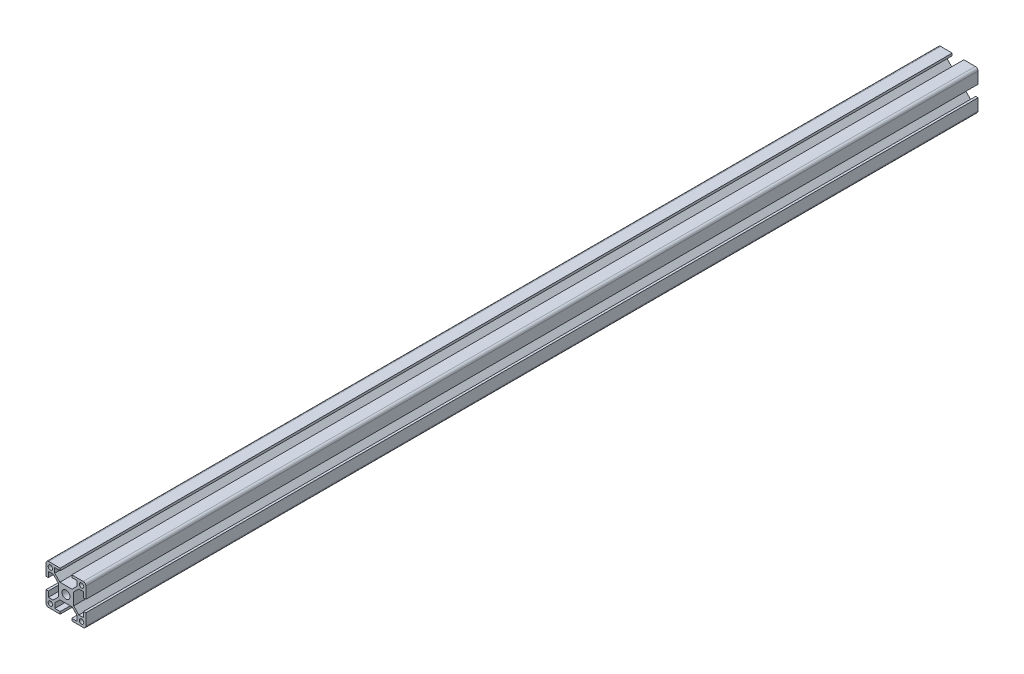
from build123d import *

# Parameters (mm, degrees)
SKETCH1_R           = 3
SKETCH1_R_2         = 1.65
BOSS_EXTRUDE1_DEPTH = 670
FILLET1_R           = 2


with BuildPart() as part:
    # Sketch1 → Boss-Extrude1 (new body)
    with BuildSketch(Plane.XY):
        Polygon((-8.46, 9.66), (-4.55, 5.75), (4.55, 5.75), (8.46, 9.66), (8.46, 13.26), (4.35, 13.26), (4.35, 15), (15, 15), (15, 4.35), (13.26, 4.35), (13.26, 8.46), (9.66, 8.46), (5.75, 4.55), (5.75, -4.55), (9.66, -8.46), (13.26, -8.46), (13.26, -4.35), (15, -4.35), (15, -15), (4.35, -15), (4.35, -13.26), (8.46, -13.26), (8.46, -9.59186747), (4.61813253, -5.75), (-4.578313253, -5.75), (-8.420180723, -9.59186747), (-8.420180723, -13.26), (-4.35, -13.26), (-4.35, -15), (-15, -15), (-15, -4.35), (-13.26, -4.35), (-13.26, -8.46), (-9.66, -8.46), (-5.75, -4.55), (-5.75, 4.55), (-9.66, 8.46), (-13.26, 8.46), (-13.26, 4.35), (-15, 4.35), (-15, 15), (-4.35, 15), (-4.35, 13.26), (-8.46, 13.26), align=None)
        Circle(SKETCH1_R, mode=Mode.SUBTRACT)
        with Locations((11.73, 11.73)):
            Circle(SKETCH1_R_2, mode=Mode.SUBTRACT)
        with Locations((11.73, -11.73)):
            Circle(SKETCH1_R_2, mode=Mode.SUBTRACT)
        with Locations((-11.73, -11.73)):
            Circle(SKETCH1_R_2, mode=Mode.SUBTRACT)
        with Locations((-11.73, 11.73)):
            Circle(SKETCH1_R_2, mode=Mode.SUBTRACT)
    extrude(amount=BOSS_EXTRUDE1_DEPTH)

    # Fillet1
    fillet1_edges = [part.edges().sort_by_distance(p)[0] for p in [
        (15, 15, 335),
        (15, -15, 335),
        (-15, -15, 335),
        (-15, 15, 335),
    ]]
    fillet(fillet1_edges, radius=FILLET1_R)


solid = part.part
